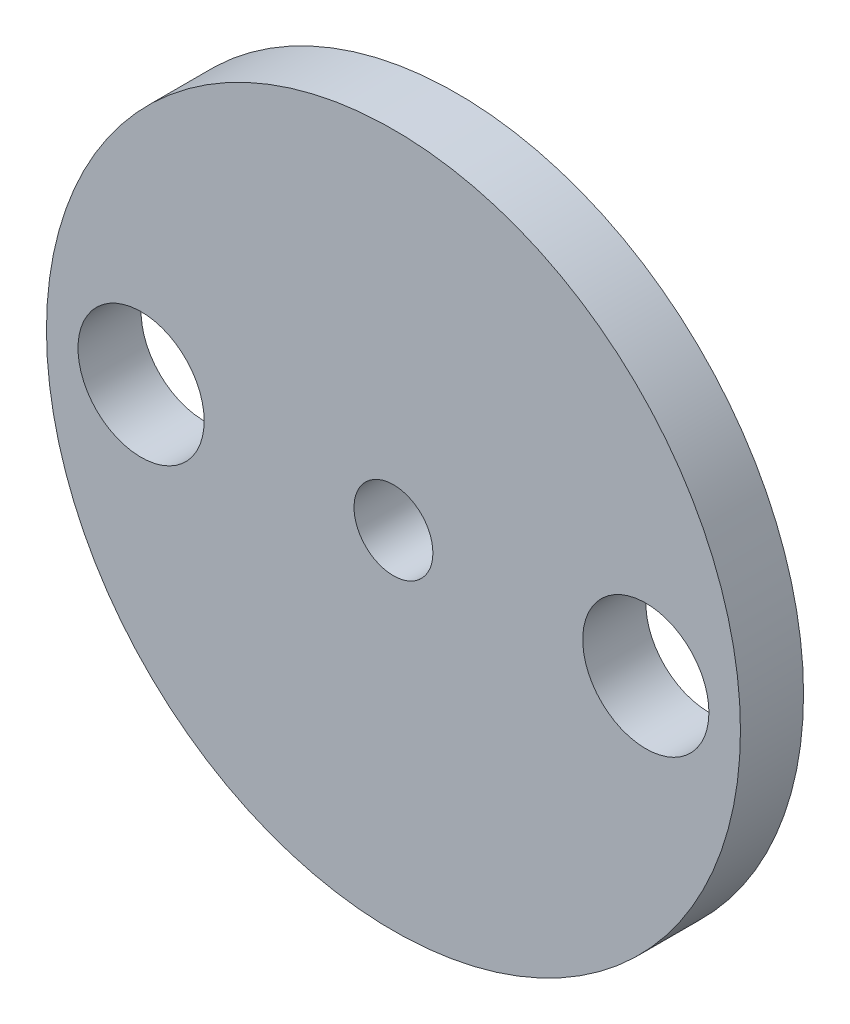
from build123d import *

# Parameters (mm, degrees)
MODEL_R             = 11
MODEL_R_2           = 2
MODEL_R_3           = 1.25
BOSS_EXTRUDE1_DEPTH = 2


with BuildPart() as part:
    # Model → Boss-Extrude1 (new body)
    with BuildSketch(Plane.XY):
        Circle(MODEL_R)
        with Locations((8, 0)):
            Circle(MODEL_R_2, mode=Mode.SUBTRACT)
        with Locations((-8, 0)):
            Circle(MODEL_R_2, mode=Mode.SUBTRACT)
        Circle(MODEL_R_3, mode=Mode.SUBTRACT)
    extrude(amount=BOSS_EXTRUDE1_DEPTH)


solid = part.part
